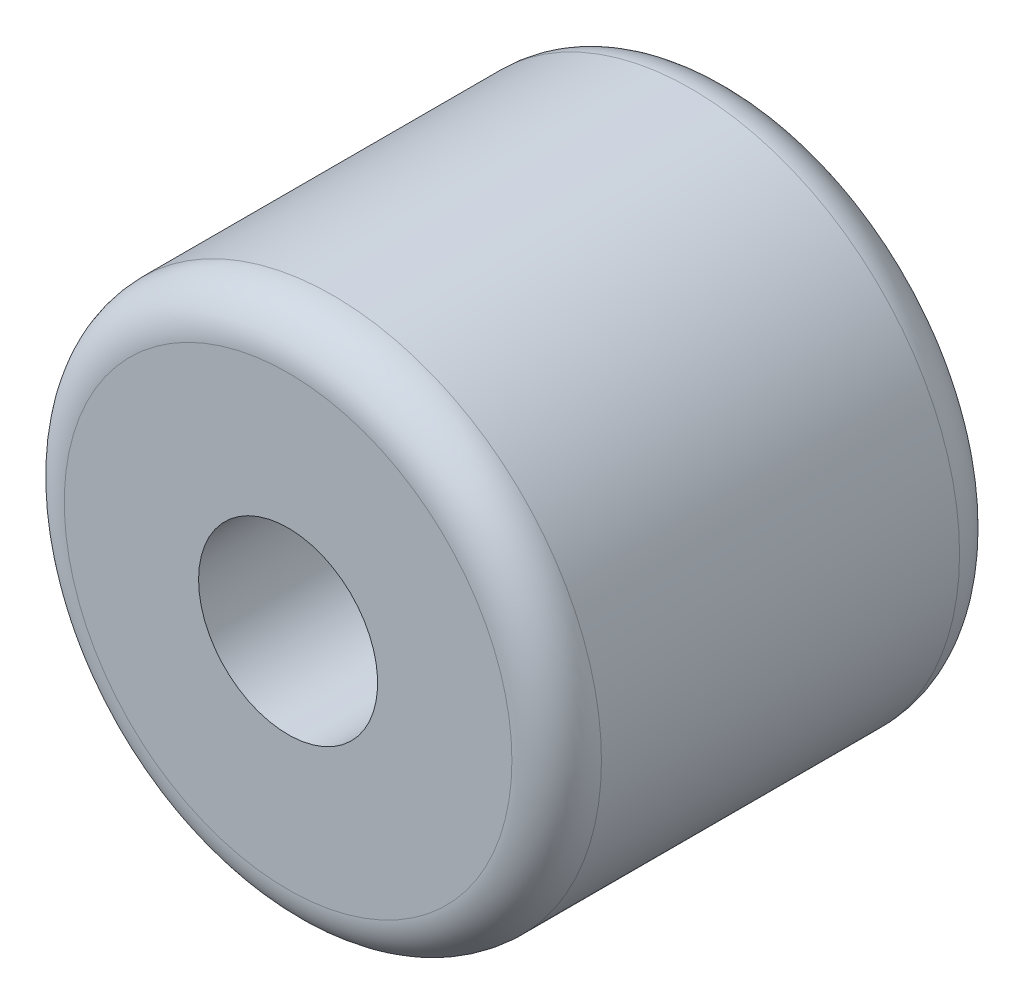
from build123d import *

# Parameters (mm, degrees)
SKETCH_1_R          = 6
EXTRUDE_1_DEPTH     = 10
SKETCH_2_R          = 2
CUT_EXTRUDE_1_DEPTH = 11
FILLET_1_R          = 1


with BuildPart() as part:
    # 草图1 → 凸台-拉伸1 (new body)
    with BuildSketch(Plane.XY):
        Circle(SKETCH_1_R)
    extrude(amount=EXTRUDE_1_DEPTH)

    # 草图2 → 切除-拉伸1 (cut, through all)
    with BuildSketch(Plane(origin=(0, 0, 0), x_dir=(-1, 0, 0), z_dir=(0, 0, -1))):
        Circle(SKETCH_2_R)
    extrude(amount=-CUT_EXTRUDE_1_DEPTH, mode=Mode.SUBTRACT)

    # 圆角1
    fillet_1_edges = [part.edges().sort_by_distance(p)[0] for p in [
        (-6, 0, 0),
        (-6, 0, 10),
    ]]
    fillet(fillet_1_edges, radius=FILLET_1_R)


solid = part.part
